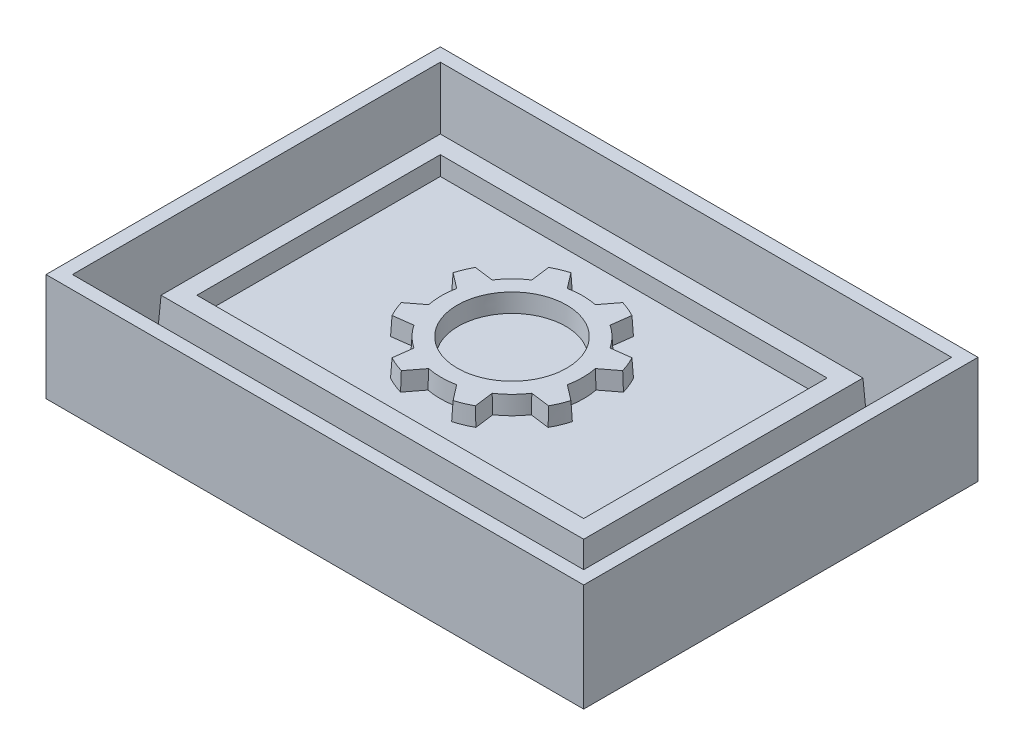
from build123d import *

# Parameters (mm, degrees)
SKETCH1_W           = 76.2
SKETCH1_H           = 50.8
BOSS_EXTRUDE1_DEPTH = 12.7
BOSS_EXTRUDE1_TAPER = 3
SKETCH2_W           = 95.25
SKETCH2_H           = 69.85
BOSS_EXTRUDE2_DEPTH = 3.175
SKETCH3_W           = 95.25
SKETCH3_H           = 69.85
SKETCH3_W_2         = 88.9
SKETCH3_H_2         = 63.5
BOSS_EXTRUDE3_DEPTH = 15.875
DRAFT1_ANGLE        = 3
SKETCH4_W           = 68.518842406
SKETCH4_H           = 43.118842406
CUT_EXTRUDE1_DEPTH  = 3.175
CUT_EXTRUDE1_DRAFT  = -3
SKETCH6_R           = 12.7
SKETCH6_R_2         = 9.525
BOSS_EXTRUDE5_DEPTH = 3.175
BOSS_EXTRUDE6_REACH = 108.018
CIRPATTERN1_COUNT   = 8
DRAFT2_ANGLE        = 3


with BuildPart() as part:
    # Sketch1 → Boss-Extrude1 (new body)
    with BuildSketch(Plane(origin=(0, 0, 0), x_dir=(1, 0, 0), z_dir=(0, 1, 0))):
        with Locations((38.1, 25.4)):
            Rectangle(SKETCH1_W, SKETCH1_H)
    extrude(amount=BOSS_EXTRUDE1_DEPTH, taper=BOSS_EXTRUDE1_TAPER)

    # Sketch2 → Boss-Extrude2 (add)
    with BuildSketch(Plane.XZ):
        with Locations((38.1, -25.4)):
            Rectangle(SKETCH2_W, SKETCH2_H)
    extrude(amount=BOSS_EXTRUDE2_DEPTH)

    # Sketch3 → Boss-Extrude3 (add)
    with BuildSketch(Plane(origin=(0, 0, 0), x_dir=(1, 0, 0), z_dir=(0, 1, 0))):
        with Locations((38.1, 25.4)):
            Rectangle(SKETCH3_W, SKETCH3_H)
        with Locations((38.1, 25.4)):
            Rectangle(SKETCH3_W_2, SKETCH3_H_2, mode=Mode.SUBTRACT)
    extrude(amount=BOSS_EXTRUDE3_DEPTH)

    # Draft1
    draft1_faces = [part.faces().sort_by_distance(p)[0] for p in [
        (82.55, 7.9375, -25.4),
        (38.1, 7.9375, -57.15),
        (38.1, 7.9375, 6.35),
        (-6.35, 7.9375, -25.4),
    ]]
    draft(draft1_faces, Plane.ZX, DRAFT1_ANGLE)


with BuildPart() as cut_extrude1_tool:
    # Sketch4 → Cut-Extrude1 (with draft: the straight prism first)
    with BuildSketch(Plane(origin=(0, 12.7, 0), x_dir=(1, 0, 0), z_dir=(0, 1, 0))):
        with Locations((38.1, 25.4)):
            Rectangle(SKETCH4_W, SKETCH4_H)
    extrude(amount=-CUT_EXTRUDE1_DEPTH)
    # Cut-Extrude1: the draft: its side faces are tilted about the plane it starts from
    cut_extrude1_sides = [cut_extrude1_tool.faces().sort_by_distance(p)[0] for p in [
        (3.840578797, 11.1125, -25.4),
        (38.1, 11.1125, -3.840578797),
        (72.359421203, 11.1125, -25.4),
        (38.1, 11.1125, -46.959421203),
    ]]
    draft(cut_extrude1_sides, Plane(origin=(0, 12.7, 0), x_dir=(1, 0, 0), z_dir=(0, 1, 0)), CUT_EXTRUDE1_DRAFT)


with BuildPart() as part_1:
    add(part.part)

    # Cut-Extrude1: cut by cut_extrude1_tool
    add(cut_extrude1_tool.part, mode=Mode.SUBTRACT)

    # Sketch6 → Boss-Extrude5 (add)
    with BuildSketch(Plane(origin=(0, 9.525, 0), x_dir=(1, 0, 0), z_dir=(0, 1, 0))):
        with Locations(Location((38.1, 25.4, 0), (0, 0, 90))):
            Circle(SKETCH6_R)
        with Locations(Location((38.1, 25.4, 0), (0, 0, 90))):
            Circle(SKETCH6_R_2, mode=Mode.SUBTRACT)
    extrude(amount=BOSS_EXTRUDE5_DEPTH)

    # Sketch7 → Boss-Extrude6 (add, up to next)
    with BuildSketch(Plane(origin=(0, 12.7, 0), x_dir=(1, 0, 0), z_dir=(0, 1, 0)), mode=Mode.PRIVATE) as boss_extrude6_sk1:
        with BuildLine():
            Line((42.624193754, 40.616678214), (40.51523203, 37.868225786))
            ThreePointArc((40.51523203, 37.868225786), (42.960079591, 37.133270063), (45.208540056, 35.924193949))
            Line((45.208540056, 35.924193949), (45.66072827, 39.358904435))
            ThreePointArc((45.66072827, 39.358904435), (44.175099489, 40.066587579), (42.624193754, 40.616678214))
        make_face()
    boss_extrude6_tool1 = extrude(boss_extrude6_sk1.sketch, amount=-BOSS_EXTRUDE6_REACH, mode=Mode.PRIVATE) - part_1.part
    boss_extrude6 = boss_extrude6_tool1.solids().sort_by_distance((43.502556, 12.7, -38.442924))[0]
    add(boss_extrude6)

    # CirPattern1: Boss-Extrude6 ×8 about axis
    cirpattern1_axis = Axis((38.1, 0, -25.4), (0, 1, 0))
    for i in range(1, CIRPATTERN1_COUNT):
        add(boss_extrude6.rotate(cirpattern1_axis, i * 360 / CIRPATTERN1_COUNT))

    # Draft2
    draft2_faces = [part_1.faces().sort_by_distance(p)[0] for p in [
        (30.765365837, 11.1125, -37.641549192),
        (32.024900511, 11.1125, -40.066587579),
        (34.630287108, 11.1125, -39.242452),
        (50.8, 11.1125, -25.4),
        (38.1, 11.1125, -15.875),
        (47.080256121, 11.1125, -34.380256121),
        (45.434634163, 11.1125, -37.641549192),
        (44.175099489, 11.1125, -40.066587579),
        (41.569712892, 11.1125, -39.242452),
        (38.1, 11.1125, -38.1),
        (51.942452, 11.1125, -28.869712892),
        (52.766587579, 11.1125, -31.475099489),
        (50.341549192, 11.1125, -32.734634163),
        (47.080256121, 11.1125, -16.419743879),
        (50.341549192, 11.1125, -18.065365837),
        (41.569712892, 11.1125, -11.557548),
        (52.766587579, 11.1125, -19.324900511),
        (51.942452, 11.1125, -21.930287108),
        (38.1, 11.1125, -12.7),
        (44.175099489, 11.1125, -10.733412421),
        (45.434634163, 11.1125, -13.158450808),
        (29.119743879, 11.1125, -16.419743879),
        (30.765365837, 11.1125, -13.158450808),
        (32.024900511, 11.1125, -10.733412421),
        (34.630287108, 11.1125, -11.557548),
        (25.4, 11.1125, -25.4),
        (24.257548, 11.1125, -21.930287108),
        (23.433412421, 11.1125, -19.324900511),
        (25.858450808, 11.1125, -18.065365837),
        (29.119743879, 11.1125, -34.380256121),
        (25.858450808, 11.1125, -32.734634163),
        (23.433412421, 11.1125, -31.475099489),
        (24.257548, 11.1125, -28.869712892),
    ]]
    draft(draft2_faces, Plane.ZX.offset(9.525), DRAFT2_ANGLE)


solid = part_1.part
